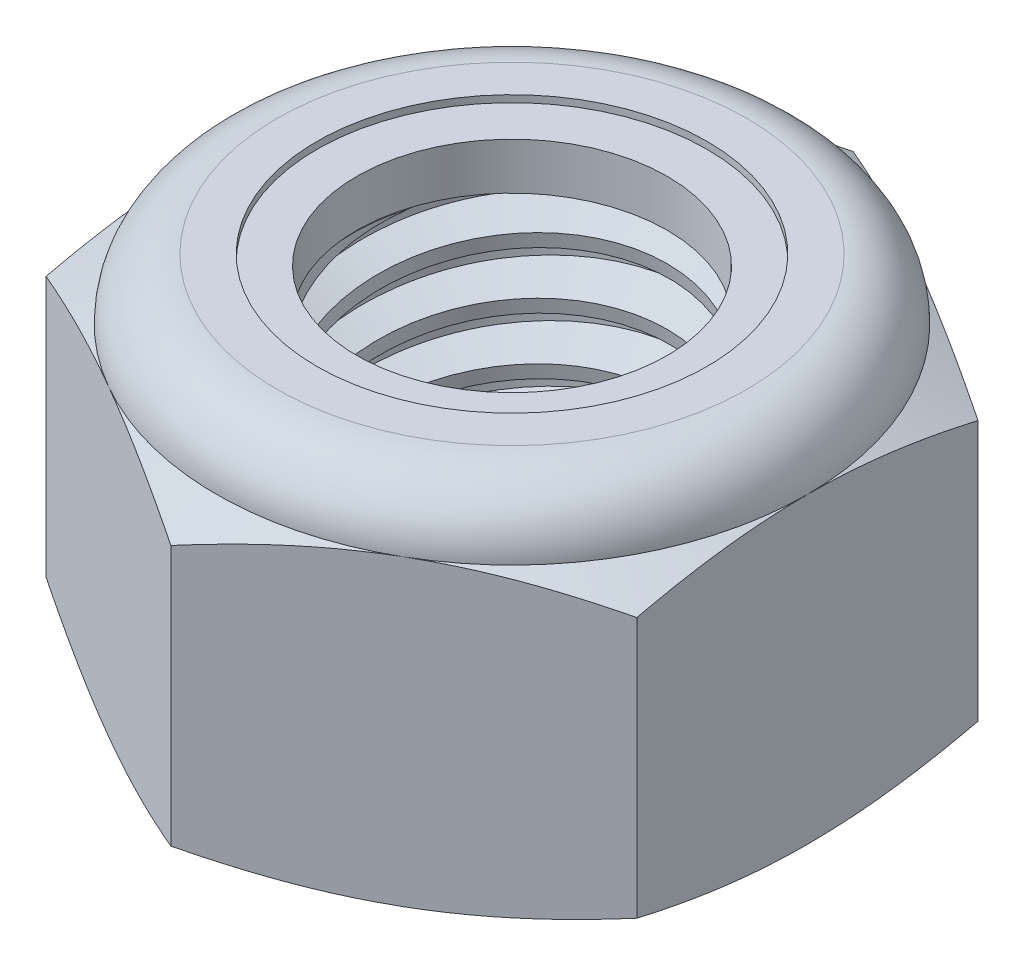
from build123d import *

# Parameters (mm, degrees)
EXTRUDE1_DEPTH       = 8
SKETCH2_W            = 4
SKETCH2_H            = 8
LPATTERN1_COUNT      = 6
LPATTERN1_PITCH      = 1.25
LPATTERN1_COUNT_DIR2 = 2
LPATTERN1_PITCH_DIR2 = 1.25


with BuildPart() as part:
    # Sketch1 → Extrude1 (new body)
    with BuildSketch(Plane(origin=(0, 0, 0), x_dir=(1, 0, 0), z_dir=(0, 1, 0))):
        Polygon((0, 7.505553499), (-6.5, 3.75277675), (-6.5, -3.75277675), (0, -7.505553499), (6.5, -3.75277675), (6.5, 3.75277675), align=None)
    extrude(amount=EXTRUDE1_DEPTH)

    # Sketch4 → Cut-Revolve2 (revolve, cut)
    with BuildSketch(Plane(origin=(0, 0, 0), x_dir=(0, 0, -1), z_dir=(1, 0, 0))):
        Polygon((0, 8), (4, 8), (3.415953356, 7.727654577), (3.415953356, 0.272345423), (4, 0), (0, 0), align=None)
    revolve(axis=Axis((0, 8, 0), (0, 1, 0)), mode=Mode.SUBTRACT)


with BuildPart() as body_2:
    # Sketch2 → Revolve1 (revolve)
    with BuildSketch(Plane(origin=(0, 0, 0), x_dir=(0, 0, -1), z_dir=(1, 0, 0))):
        with Locations((2, 4)):
            Rectangle(SKETCH2_W, SKETCH2_H)
    revolve(axis=Axis((0, -4, 0), (0, 1, 0)))

    # Sketch3 → Cut-Revolve1 (revolve, cut)
    with BuildSketch(Plane(origin=(0, 0, 0), x_dir=(0, 0, -1), z_dir=(1, 0, 0))):
        Polygon((4.024121388, 7.84562312), (4.1929711, 6.764984958), (3.464196131, 7.046478487), (3.415953356, 7.355232247), align=None)
    cut_revolve1 = revolve(axis=Axis((0, 8, 0.208852549), (0, -0.9880120337511015, -0.15437688027360996)), mode=Mode.SUBTRACT)

    # LPattern1: Cut-Revolve1 6 × 2
    with Locations(*[Vector(0, -1, 0) * (i * LPATTERN1_PITCH) + Vector(0, 1, 0) * (j * LPATTERN1_PITCH_DIR2) for i in range(LPATTERN1_COUNT) for j in range(LPATTERN1_COUNT_DIR2) if (i, j) != (0, 0)]):
        add(cut_revolve1, mode=Mode.SUBTRACT)


with BuildPart() as part_1:
    add(part.part)

    # Combine1: cut body 2
    add(body_2.part, mode=Mode.SUBTRACT)

    # Sketch5 → Cut-Revolve3 (revolve, cut)
    with BuildSketch(Plane(origin=(0, 0, 0), x_dir=(0, 0, -1), z_dir=(1, 0, 0))):
        with BuildLine():
            Line((0, 0), (6.5, 0))
            Line((6.5, 0), (7.505553499, 0.468897297))
            Line((7.505553499, 0.468897297), (7.505553499, 6.197769369))
            Line((7.505553499, 6.197769369), (6.5, 6.666666667))
            ThreePointArc((6.5, 6.666666667), (6.109475708, 7.609475708), (5.166666667, 8))
            Line((5.166666667, 8), (5.166666667, 9.27))
            Line((5.166666667, 9.27), (8.775553499, 9.27))
            Line((8.775553499, 9.27), (8.775553499, -1.27))
            Line((8.775553499, -1.27), (0, -1.27))
            Line((0, -1.27), (0, 0))
        make_face()
    revolve(axis=Axis((0, 0, 0), (0, 1, 0)), mode=Mode.SUBTRACT)

    # Sketch6 → Cut-Revolve4 (revolve, cut)
    with BuildSketch(Plane(origin=(0, 0, 0), x_dir=(0, 0, -1), z_dir=(1, 0, 0))):
        with BuildLine():
            Line((0, 6.666666667), (6.3476, 6.666666667))
            ThreePointArc((6.3476, 6.666666667), (6.001712635, 7.501712635), (5.166666667, 7.8476))
            Line((5.166666667, 7.8476), (4.291310011, 7.8476))
            Line((4.291310011, 7.8476), (4.291310011, 9.27))
            Line((4.291310011, 9.27), (0, 9.27))
            Line((0, 9.27), (0, 6.666666667))
        make_face()
    revolve(axis=Axis((0, 9.27, 0), (0, 1, 0)), mode=Mode.SUBTRACT)


with BuildPart() as body_2_2:
    # Sketch7 → Revolve2 (revolve)
    with BuildSketch(Plane(origin=(0, 0, 0), x_dir=(0, 0, -1), z_dir=(1, 0, 0))):
        with BuildLine():
            Line((3.415953356, 6.742866667), (6.268768884, 6.742866667))
            ThreePointArc((6.268768884, 6.742866667), (5.920409016, 7.474322663), (5.166666667, 7.7714))
            Line((5.166666667, 7.7714), (3.415953356, 7.7714))
            Line((3.415953356, 7.7714), (3.415953356, 6.742866667))
        make_face()
    revolve(axis=Axis((0, 6.742866667, 0), (0, 1, 0)))


solid = Compound([part_1.part, body_2_2.part])
